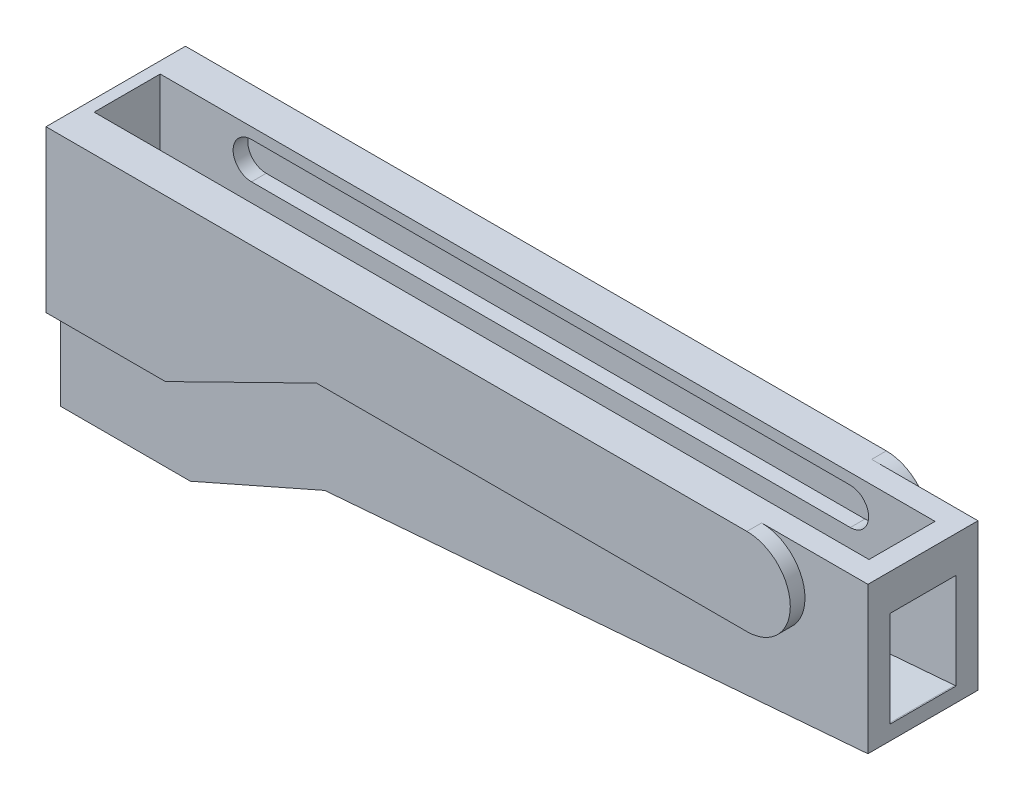
from build123d import *

# Parameters (mm, degrees)
BOSS_EXTRUDE1_START = 3
BOSS_EXTRUDE1_DEPTH = 1.5
BOSS_EXTRUDE2_DEPTH = 1
CUT_EXTRUDE1_DEPTH  = 1.5
BOSS_EXTRUDE3_START = -3
BOSS_EXTRUDE3_DEPTH = 1.5
BOSS_EXTRUDE4_DEPTH = 1
BOSS_EXTRUDE5_DEPTH = 4.5
CUT_EXTRUDE2_DEPTH  = 1
SKETCH10_W          = 0.780201508
SKETCH10_H          = 4.986255627
BOSS_EXTRUDE6_DEPTH = 4.5
SKETCH11_W          = 1.426663005
SKETCH11_H          = 2.471476461
BOSS_EXTRUDE7_DEPTH = 4.5


with BuildPart() as part:
    # Sketch1 → Boss-Extrude1 (new body)
    with BuildSketch(Plane.XY.offset(BOSS_EXTRUDE1_START)):
        Polygon((-9.513255025, -4.466723996), (-18.663811547, -8.5), (-27.5, -8.5), (-27.5, 8.5), (27.5, 8.5), (27.5, -1.5), align=None)
    extrude(amount=BOSS_EXTRUDE1_DEPTH)

    # Sketch2 → Boss-Extrude2 (add)
    with BuildSketch(Plane.XY.offset(4.5)):
        with BuildLine():
            Line((-27.5, -2.468678655), (-19.36276873, -2.468678655))
            Line((-19.36276873, -2.468678655), (-9.07165048, 2.587651121))
            Line((-9.07165048, 2.587651121), (20.25506222, 2.587651121))
            ThreePointArc((20.25506222, 2.587651121), (23.21123666, 5.54382556), (20.25506222, 8.5))
            Line((20.25506222, 8.5), (-27.5, 8.5))
            Line((-27.5, 8.5), (-27.5, -2.468678655))
        make_face()
    extrude(amount=BOSS_EXTRUDE2_DEPTH)

    # Sketch3 → Cut-Extrude1 (cut)
    with BuildSketch(Plane(origin=(0, 0, 3), x_dir=(-1, 0, 0), z_dir=(0, 0, -1))):
        with BuildLine():
            Line((-20.296822584, 7.75), (20.5, 7.75))
            ThreePointArc((20.5, 7.75), (21.75, 6.5), (20.5, 5.25))
            Line((20.5, 5.25), (-20.296822584, 5.25))
            ThreePointArc((-20.296822584, 5.25), (-21.546822584, 6.5), (-20.296822584, 7.75))
        make_face()
    extrude(amount=-CUT_EXTRUDE1_DEPTH, mode=Mode.SUBTRACT)



with BuildPart() as body_2:
    # Sketch5 → Boss-Extrude3 (new body)
    with BuildSketch(Plane.XY.offset(BOSS_EXTRUDE3_START)):
        Polygon((27.5, -1.5), (-9.513255025, -4.466723996), (-18.663811547, -8.5), (-27.5, -8.5), (-27.5, 8.5), (27.5, 8.5), align=None)
    extrude(amount=BOSS_EXTRUDE3_DEPTH)

    # Sketch7 → Boss-Extrude4 (add)
    with BuildSketch(Plane(origin=(0, 0, -3), x_dir=(-1, 0, 0), z_dir=(0, 0, -1))):
        with BuildLine():
            Line((-20.25506222, 8.5), (27.5, 8.5))
            Line((27.5, 8.5), (27.5, -2.468678655))
            Line((27.5, -2.468678655), (19.36276873, -2.468678655))
            Line((19.36276873, -2.468678655), (9.07165048, 2.587651121))
            Line((9.07165048, 2.587651121), (-20.25506222, 2.587651121))
            ThreePointArc((-20.25506222, 2.587651121), (-23.21123666, 5.54382556), (-20.25506222, 8.5))
        make_face()
    extrude(amount=BOSS_EXTRUDE4_DEPTH)


with BuildPart() as part_1:
    add(part.part)

    add(body_2.part)  # Boss-Extrude5 merges body 2
    # Sketch8 → Boss-Extrude5 (add)
    with BuildSketch(Plane(origin=(0, 0, 3), x_dir=(-1, 0, 0), z_dir=(0, 0, -1))):
        Polygon((-27.5, -0.503196857), (-27.5, -1.5), (9.513255025, -4.466723996), (18.663811547, -8.5), (27.5, -8.5), (27.5, -7.5), (26.5, -7.5), (18.874420362, -7.5), (9.761781861, -3.483437061), (-27.420103222, -0.503196857), align=None)
    extrude(amount=BOSS_EXTRUDE5_DEPTH)

    # Sketch9 → Cut-Extrude2 (cut)
    with BuildSketch(Plane.XY.offset(-1.5)):
        with BuildLine():
            Line((-20.5, 7.75), (20.296822584, 7.75))
            ThreePointArc((20.296822584, 7.75), (21.546822584, 6.5), (20.296822584, 5.25))
            Line((20.296822584, 5.25), (-20.5, 5.25))
            ThreePointArc((-20.5, 5.25), (-21.75, 6.5), (-20.5, 7.75))
        make_face()
    extrude(amount=-CUT_EXTRUDE2_DEPTH, mode=Mode.SUBTRACT)

    # Sketch10 → Boss-Extrude6 (add)
    with BuildSketch(Plane(origin=(0, 0, 3), x_dir=(-1, 0, 0), z_dir=(0, 0, -1))):
        with Locations((27.109899246, 6.006872186)):
            Rectangle(SKETCH10_W, SKETCH10_H)
    extrude(amount=BOSS_EXTRUDE6_DEPTH)

    # Sketch11 → Boss-Extrude7 (add)
    with BuildSketch(Plane.XY.offset(-1.5)):
        with Locations((26.786668498, 7.26426177)):
            Rectangle(SKETCH11_W, SKETCH11_H)
    extrude(amount=BOSS_EXTRUDE7_DEPTH)


solid = part_1.part
